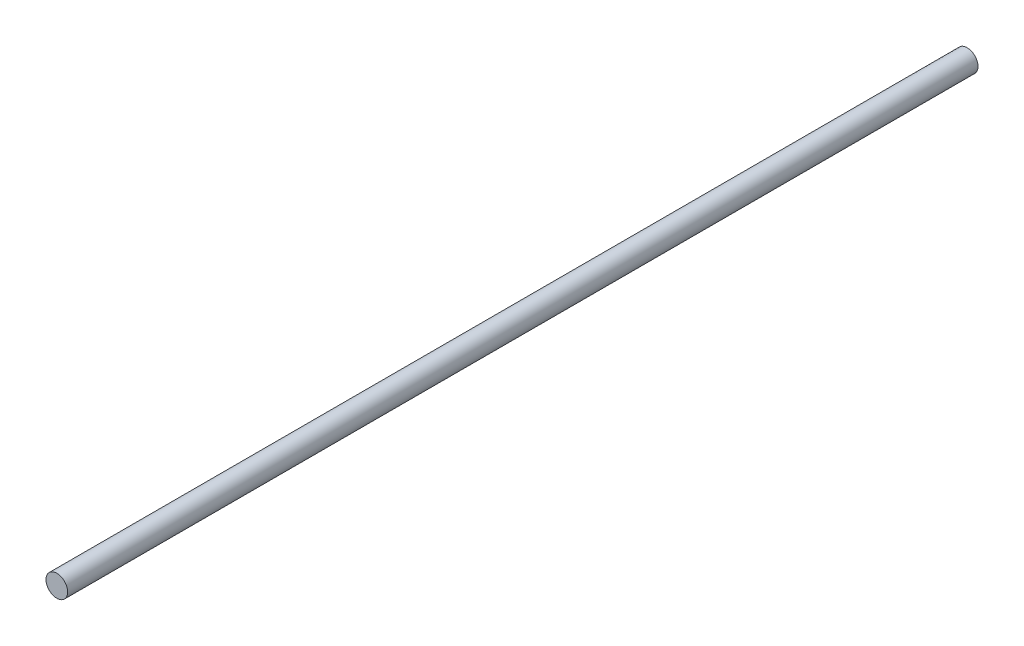
from build123d import *

# Parameters (mm, degrees)
SKETCH1_R      = 3.175
EXTRUDE1_DEPTH = 133.35


with BuildPart() as part:
    # Sketch1 → Extrude1 (new body, symmetric)
    with BuildSketch(Plane.XY):
        Circle(SKETCH1_R)
    extrude(amount=EXTRUDE1_DEPTH, both=True)


solid = part.part
